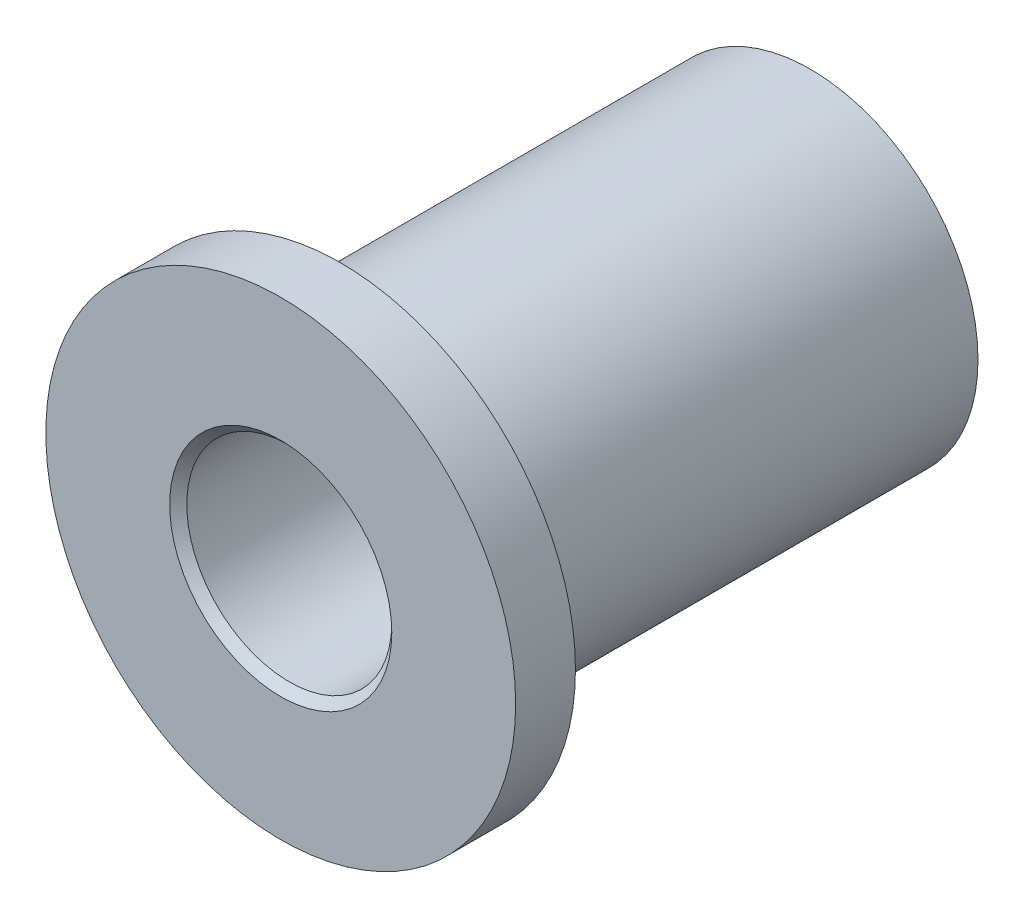
from build123d import *

# Parameters (mm, degrees)
SKETCH1_R          = 5.5
EXTRUDE1_DEPTH     = 1.4
SKETCH2_R          = 3.925
EXTRUDE2_DEPTH     = 11
SKETCH4_R          = 2.4
CUT_EXTRUDE1_DEPTH = 13.4
CHAMFER1_SIZE      = 0.2


with BuildPart() as part:
    # Sketch1 → Extrude1 (new body)
    with BuildSketch(Plane.XY):
        Circle(SKETCH1_R)
    extrude(amount=-EXTRUDE1_DEPTH)

    # Sketch2 → Extrude2 (add)
    with BuildSketch(Plane(origin=(0, 0, -1.4), x_dir=(-1, 0, 0), z_dir=(0, 0, -1))):
        Circle(SKETCH2_R)
    extrude(amount=EXTRUDE2_DEPTH)

    # Sketch4 → Cut-Extrude1 (cut, through all)
    with BuildSketch(Plane.XY):
        Circle(SKETCH4_R)
    extrude(amount=-CUT_EXTRUDE1_DEPTH, mode=Mode.SUBTRACT)

    # Chamfer1
    chamfer1_edges = [part.edges().sort_by_distance(p)[0] for p in [
        (-2.4, 0, 0),
    ]]
    chamfer(chamfer1_edges, length=CHAMFER1_SIZE)


solid = part.part
